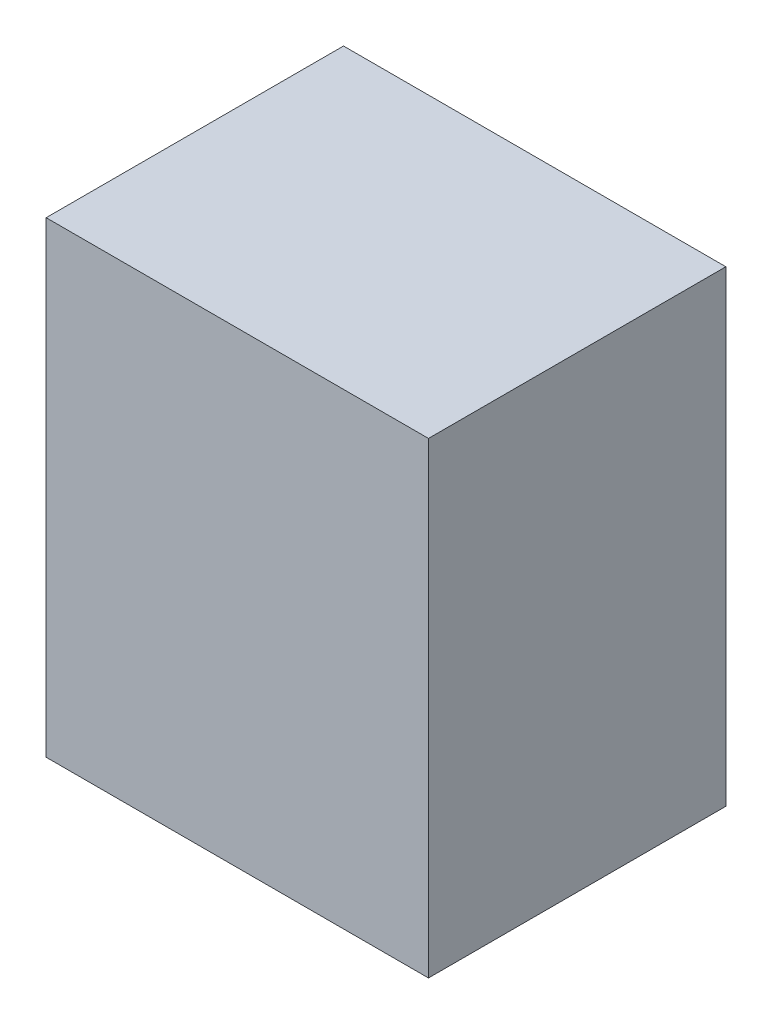
from build123d import *

# Parameters (mm, degrees)
ESQUISSE1_W        = 90
ESQUISSE1_H        = 110
BOSS_EXTRU_1_DEPTH = 70


with BuildPart() as part:
    # Esquisse1 → Boss.-Extru.1 (new body)
    with BuildSketch(Plane.XY):
        with Locations((6.991463889, -23.043478261)):
            Rectangle(ESQUISSE1_W, ESQUISSE1_H)
    extrude(amount=BOSS_EXTRU_1_DEPTH)


solid = part.part
